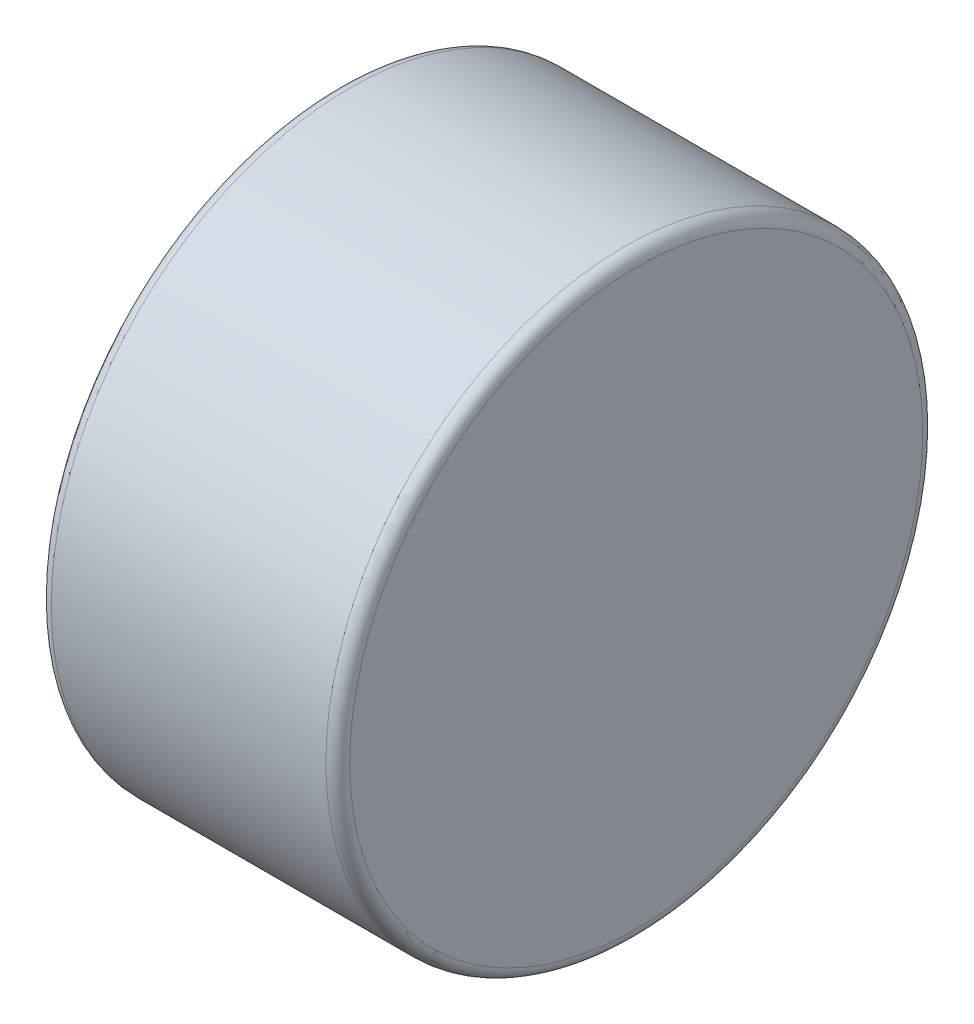
from build123d import *

# Parameters (mm, degrees)
SKETCH1_R           = 5
BOSS_EXTRUDE1_DEPTH = 2.5
FILLET1_R           = 0.2


with BuildPart() as part:
    # Sketch1 → Boss-Extrude1 (new body, symmetric)
    with BuildSketch(Plane(origin=(0, 0, 0), x_dir=(0, 0, -1), z_dir=(1, 0, 0))):
        Circle(SKETCH1_R)
    extrude(amount=BOSS_EXTRUDE1_DEPTH, both=True)

    # Fillet1
    fillet1_edges = [part.edges().sort_by_distance(p)[0] for p in [
        (-2.5, 0, 5),
        (2.5, 0, 5),
    ]]
    fillet(fillet1_edges, radius=FILLET1_R)


solid = part.part
